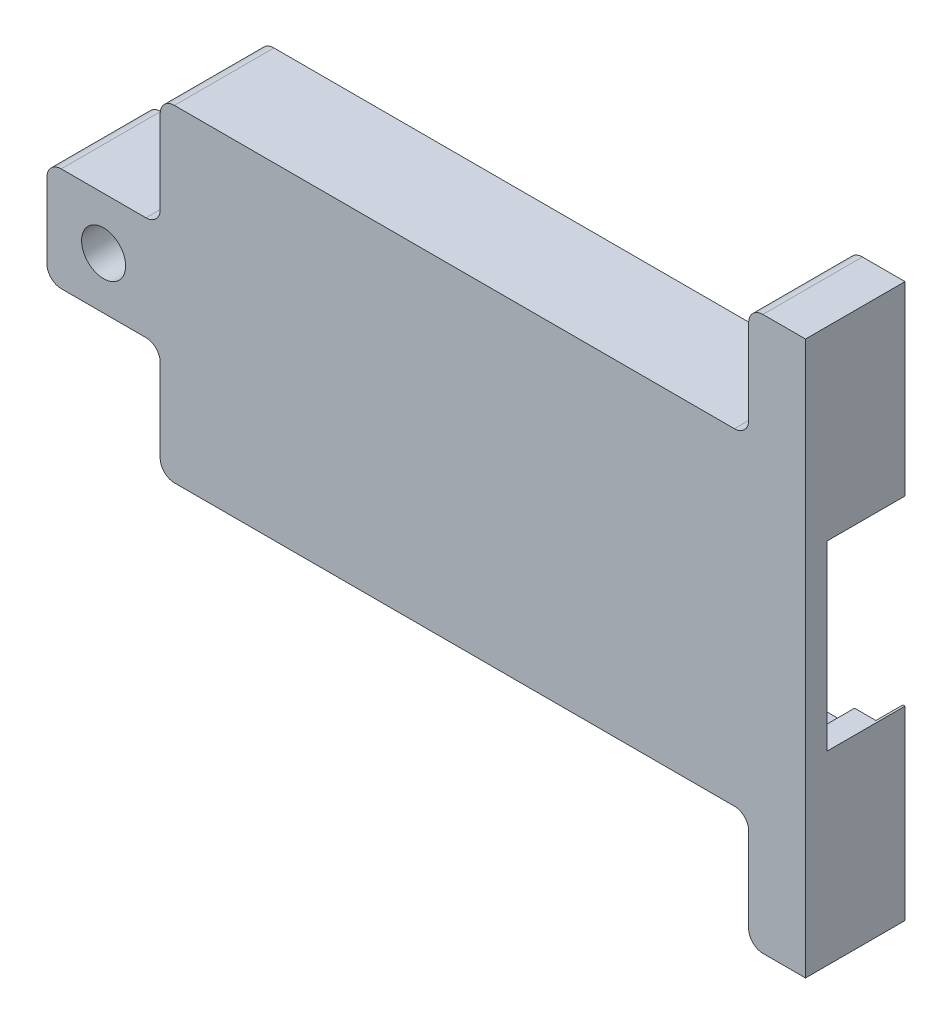
from build123d import *

# Parameters (mm, degrees)
CROQUIS1_R              = 1.55
SALIENTE_EXTRUIR1_DEPTH = 5.5
CROQUIS2_R              = 1.55
SALIENTE_EXTRUIR2_DEPTH = 1.5
CROQUIS3_W              = 43.5
CROQUIS3_H              = 19
CORTAR_EXTRUIR1_DEPTH   = 1.9
CROQUIS4_R              = 1.5
CORTAR_EXTRUIR2_DEPTH   = 3
CHAFL_N1_SIZE           = 0.4


with BuildPart() as part:
    # Croquis1 → Saliente-Extruir1 (new body)
    with BuildSketch(Plane.XY):
        with BuildLine():
            Line((16.15, 11.5), (-23.25, 11.5))
            ThreePointArc((-23.25, 11.5), (-23.957106781, 11.207106781), (-24.25, 10.5))
            Line((-24.25, 10.5), (-24.25, 4.65))
            ThreePointArc((-24.25, 4.65), (-24.542893219, 3.942893219), (-25.25, 3.65))
            Line((-25.25, 3.65), (-31.215212315, 3.65))
            ThreePointArc((-31.215212315, 3.65), (-31.922319096, 3.357106781), (-32.215212315, 2.65))
            Line((-32.215212315, 2.65), (-32.215212315, -2.65))
            ThreePointArc((-32.215212315, -2.65), (-31.922319096, -3.357106781), (-31.215212315, -3.65))
            Line((-31.215212315, -3.65), (-25.25, -3.65))
            ThreePointArc((-25.25, -3.65), (-24.542893219, -3.942893219), (-24.25, -4.65))
            Line((-24.25, -4.65), (-24.25, -10.5))
            ThreePointArc((-24.25, -10.5), (-23.957106781, -11.207106781), (-23.25, -11.5))
            Line((-23.25, -11.5), (16.15, -11.5))
            ThreePointArc((16.15, -11.5), (16.857106781, -11.792893219), (17.15, -12.5))
            Line((17.15, -12.5), (17.15, -18.465212315))
            ThreePointArc((17.15, -18.465212315), (17.442893219, -19.172319096), (18.15, -19.465212315))
            Line((18.15, -19.465212315), (21.15, -19.465212315))
            Line((21.15, -19.465212315), (21.15, -6.4))
            Line((21.15, -6.4), (19.5, -6.4))
            Line((19.5, -6.4), (19.5, -9.5))
            Line((19.5, -9.5), (-19.5, -9.5))
            Line((-19.5, -9.5), (-19.5, -6.4))
            Line((-19.5, -6.4), (-22.5, -6.4))
            Line((-22.5, -6.4), (-22.5, 6.4))
            Line((-22.5, 6.4), (-19.5, 6.4))
            Line((-19.5, 6.4), (-19.5, 9.5))
            Line((-19.5, 9.5), (19.5, 9.5))
            Line((19.5, 9.5), (19.5, 6.4))
            Line((19.5, 6.4), (21.15, 6.4))
            Line((21.15, 6.4), (21.15, 19.465212315))
            Line((21.15, 19.465212315), (18.15, 19.465212315))
            ThreePointArc((18.15, 19.465212315), (17.442893219, 19.172319096), (17.15, 18.465212315))
            Line((17.15, 18.465212315), (17.15, 12.5))
            ThreePointArc((17.15, 12.5), (16.857106781, 11.792893219), (16.15, 11.5))
        make_face()
        with Locations((-28.232606158, 0)):
            Circle(CROQUIS1_R, mode=Mode.SUBTRACT)
    extrude(amount=SALIENTE_EXTRUIR1_DEPTH)

    # Croquis2 → Saliente-Extruir2 (add)
    with BuildSketch(Plane.XY.offset(5.5)):
        with BuildLine():
            Line((21.15, -6.4), (21.15, 6.4))
            Line((21.15, 6.4), (21.15, 19.465212315))
            Line((21.15, 19.465212315), (18.15, 19.465212315))
            ThreePointArc((18.15, 19.465212315), (17.442893219, 19.172319096), (17.15, 18.465212315))
            Line((17.15, 18.465212315), (17.15, 12.5))
            ThreePointArc((17.15, 12.5), (16.857106781, 11.792893219), (16.15, 11.5))
            Line((16.15, 11.5), (-23.25, 11.5))
            ThreePointArc((-23.25, 11.5), (-23.957106781, 11.207106781), (-24.25, 10.5))
            Line((-24.25, 10.5), (-24.25, 4.65))
            ThreePointArc((-24.25, 4.65), (-24.542893219, 3.942893219), (-25.25, 3.65))
            Line((-25.25, 3.65), (-31.215212315, 3.65))
            ThreePointArc((-31.215212315, 3.65), (-31.922319096, 3.357106781), (-32.215212315, 2.65))
            Line((-32.215212315, 2.65), (-32.215212315, -2.65))
            ThreePointArc((-32.215212315, -2.65), (-31.922319096, -3.357106781), (-31.215212315, -3.65))
            Line((-31.215212315, -3.65), (-25.25, -3.65))
            ThreePointArc((-25.25, -3.65), (-24.542893219, -3.942893219), (-24.25, -4.65))
            Line((-24.25, -4.65), (-24.25, -10.5))
            ThreePointArc((-24.25, -10.5), (-23.957106781, -11.207106781), (-23.25, -11.5))
            Line((-23.25, -11.5), (16.15, -11.5))
            ThreePointArc((16.15, -11.5), (16.857106781, -11.792893219), (17.15, -12.5))
            Line((17.15, -12.5), (17.15, -18.465212315))
            ThreePointArc((17.15, -18.465212315), (17.442893219, -19.172319096), (18.15, -19.465212315))
            Line((18.15, -19.465212315), (21.15, -19.465212315))
            Line((21.15, -19.465212315), (21.15, -6.4))
        make_face()
        with Locations((-28.232606158, 0)):
            Circle(CROQUIS2_R, mode=Mode.SUBTRACT)
    extrude(amount=SALIENTE_EXTRUIR2_DEPTH)

    # Croquis3 → Cortar-Extruir1 (cut)
    with BuildSketch(Plane(origin=(0, 0, 0), x_dir=(-1, 0, 0), z_dir=(0, 0, -1))):
        with Locations((0.75, 0)):
            Rectangle(CROQUIS3_W, CROQUIS3_H)
    extrude(amount=-CORTAR_EXTRUIR1_DEPTH, mode=Mode.SUBTRACT)

    # Croquis4 → Cortar-Extruir2 (cut)
    with BuildSketch(Plane(origin=(0, 0, 0), x_dir=(-1, 0, 0), z_dir=(0, 0, -1))):
        with Locations((-19.15, -14.965212315)):
            Circle(CROQUIS4_R)
        with Locations((-19.15, 14.965212315)):
            Circle(CROQUIS4_R)
    extrude(amount=-CORTAR_EXTRUIR2_DEPTH, mode=Mode.SUBTRACT)

    # Chaflán1
    chafl_n1_edges = [part.edges().sort_by_distance(p)[0] for p in [
        (20.65, -14.965212315, 0),
        (20.65, 14.965212315, 0),
    ]]
    chamfer(chafl_n1_edges, length=CHAFL_N1_SIZE)


solid = part.part
